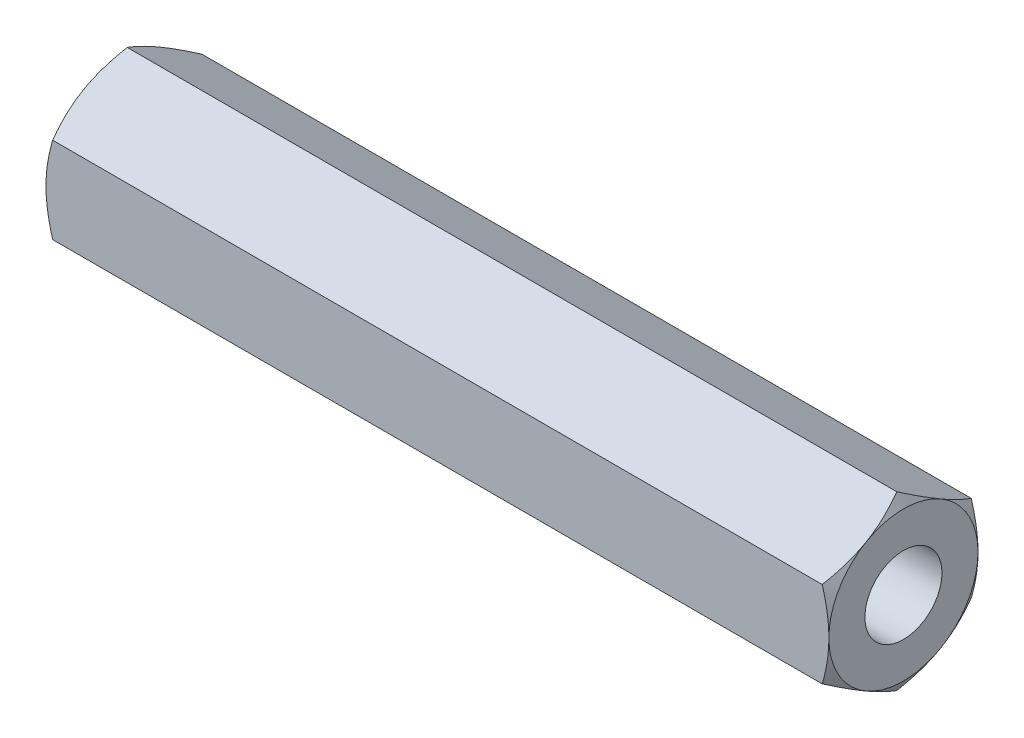
from build123d import *

# Parameters (mm, degrees)
BOSS_EXTRUDE1_DEPTH = 42
TAP1_D              = 4.134
TAP1_DEPTH          = 12.4
TAP1_TIP            = 1.2419789
TAP2_D              = 4.134
TAP2_DEPTH          = 12.4
TAP2_TIP            = 1.2419789


with BuildPart() as part:
    # Sketch1 → Boss-Extrude1 (new body)
    with BuildSketch(Plane(origin=(0, 0, 0), x_dir=(0, 0, -1), z_dir=(1, 0, 0))):
        Polygon((0, -4.618802154), (4, -2.309401077), (4, 2.309401077), (0, 4.618802154), (-4, 2.309401077), (-4, -2.309401077), align=None)
    extrude(amount=BOSS_EXTRUDE1_DEPTH)

    # Sketch2 → Cut-Revolve1 (revolve, cut)
    with BuildSketch(Plane.XY):
        Polygon((0, 4.618802154), (0.35726559, 4.618802154), (0, 4), align=None)
        Polygon((41.64273441, 4.618802154), (42, 4), (42, 4.618802154), align=None)
    revolve(axis=Axis((0, 0, 0), (1, 0, 0)), mode=Mode.SUBTRACT)

    # Tap1
    with Locations(Plane.ZY):
        with Locations((0, 0)):
            Hole(TAP1_D / 2, depth=TAP1_DEPTH)
            with Locations((0, 0, -(TAP1_DEPTH + TAP1_TIP / 2))):  # 118° drill point
                Cone(0, TAP1_D / 2, TAP1_TIP, mode=Mode.SUBTRACT)

    # Tap2
    with Locations(Plane(origin=(42, 0, 0), x_dir=(0, 0, -1), z_dir=(1, 0, 0))):
        with Locations((0, 0)):
            Hole(TAP2_D / 2, depth=TAP2_DEPTH)
            with Locations((0, 0, -(TAP2_DEPTH + TAP2_TIP / 2))):  # 118° drill point
                Cone(0, TAP2_D / 2, TAP2_TIP, mode=Mode.SUBTRACT)


solid = part.part
